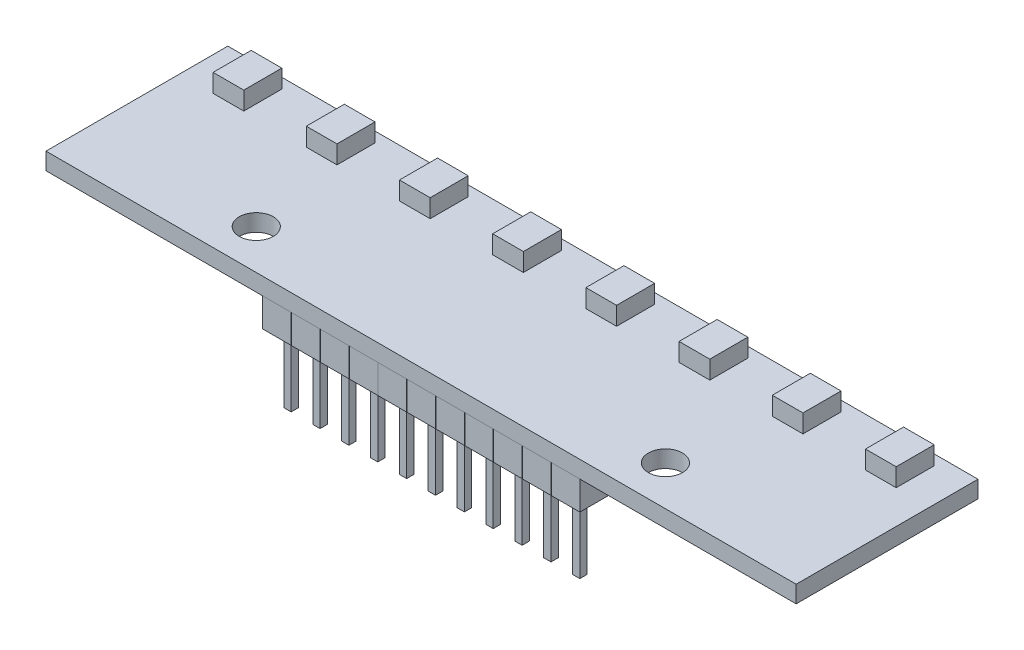
from build123d import *

# Parameters (mm, degrees)
SKETCH1_W           = 66
SKETCH1_H           = 16
SKETCH1_R           = 1.5
BOSS_EXTRUDE1_DEPTH = 1.5
SKETCH2_W           = 2.5
SKETCH2_H           = 2.5
BOSS_EXTRUDE2_DEPTH = 2.54
SKETCH3_W           = 0.64
SKETCH3_H           = 0.64
BOSS_EXTRUDE3_DEPTH = 6
LPATTERN1_COUNT     = 6
LPATTERN1_PITCH     = 2.54
LPATTERN1_COL_COUNT = 6
LPATTERN1_COL_PITCH = 2.54
SKETCH4_W           = 2.7
SKETCH4_H           = 3.35
BOSS_EXTRUDE4_DEPTH = 1.6


with BuildPart() as part:
    # Sketch1 → Boss-Extrude1 (new body)
    with BuildSketch(Plane(origin=(0, 0, 0), x_dir=(1, 0, 0), z_dir=(0, 1, 0))):
        Rectangle(SKETCH1_W, SKETCH1_H)
        with Locations((-18, -4.5)):
            Circle(SKETCH1_R, mode=Mode.SUBTRACT)
        with Locations((18, -4.5)):
            Circle(SKETCH1_R, mode=Mode.SUBTRACT)
    extrude(amount=-BOSS_EXTRUDE1_DEPTH)

    # Sketch2 → Boss-Extrude2 (add)
    with BuildSketch(Plane.XZ.offset(1.5)):
        with Locations((0, 6.73)):
            Rectangle(SKETCH2_W, SKETCH2_H)
    boss_extrude2 = extrude(amount=BOSS_EXTRUDE2_DEPTH)

    # Sketch3 → Boss-Extrude3 (add)
    with BuildSketch(Plane(origin=(0, -4.04, 0), x_dir=(-1, 0, 0), z_dir=(0, -1, 0))):
        with Locations((0, -6.73)):
            Rectangle(SKETCH3_W, SKETCH3_H)
    boss_extrude3 = extrude(amount=BOSS_EXTRUDE3_DEPTH)

    # LPattern1: Boss-Extrude2, Boss-Extrude3 ×6
    with Locations(*[(-i * LPATTERN1_PITCH, 0, 0) for i in range(1, LPATTERN1_COUNT)]):
        add(boss_extrude2)
        add(boss_extrude3)

    # LPattern1 col: Boss-Extrude2, Boss-Extrude3 ×6
    with Locations(*[(i * LPATTERN1_COL_PITCH, 0, 0) for i in range(1, LPATTERN1_COL_COUNT)]):
        add(boss_extrude2)
        add(boss_extrude3)

    # Sketch4 → Boss-Extrude4 (add)
    with BuildSketch(Plane(origin=(0, 0, 0), x_dir=(1, 0, 0), z_dir=(0, 1, 0))):
        with Locations((-4.1, 5.425)):
            Rectangle(SKETCH4_W, SKETCH4_H)
        with Locations((4.1, 5.425)):
            Rectangle(SKETCH4_W, SKETCH4_H)
        with Locations((12.3, 5.425)):
            Rectangle(SKETCH4_W, SKETCH4_H)
        with Locations((20.5, 5.425)):
            Rectangle(SKETCH4_W, SKETCH4_H)
        with Locations((28.7, 5.425)):
            Rectangle(SKETCH4_W, SKETCH4_H)
        with Locations((-12.3, 5.425)):
            Rectangle(SKETCH4_W, SKETCH4_H)
        with Locations((-28.7, 5.425)):
            Rectangle(SKETCH4_W, SKETCH4_H)
        with Locations((-20.5, 5.425)):
            Rectangle(SKETCH4_W, SKETCH4_H)
    extrude(amount=BOSS_EXTRUDE4_DEPTH)


solid = part.part
